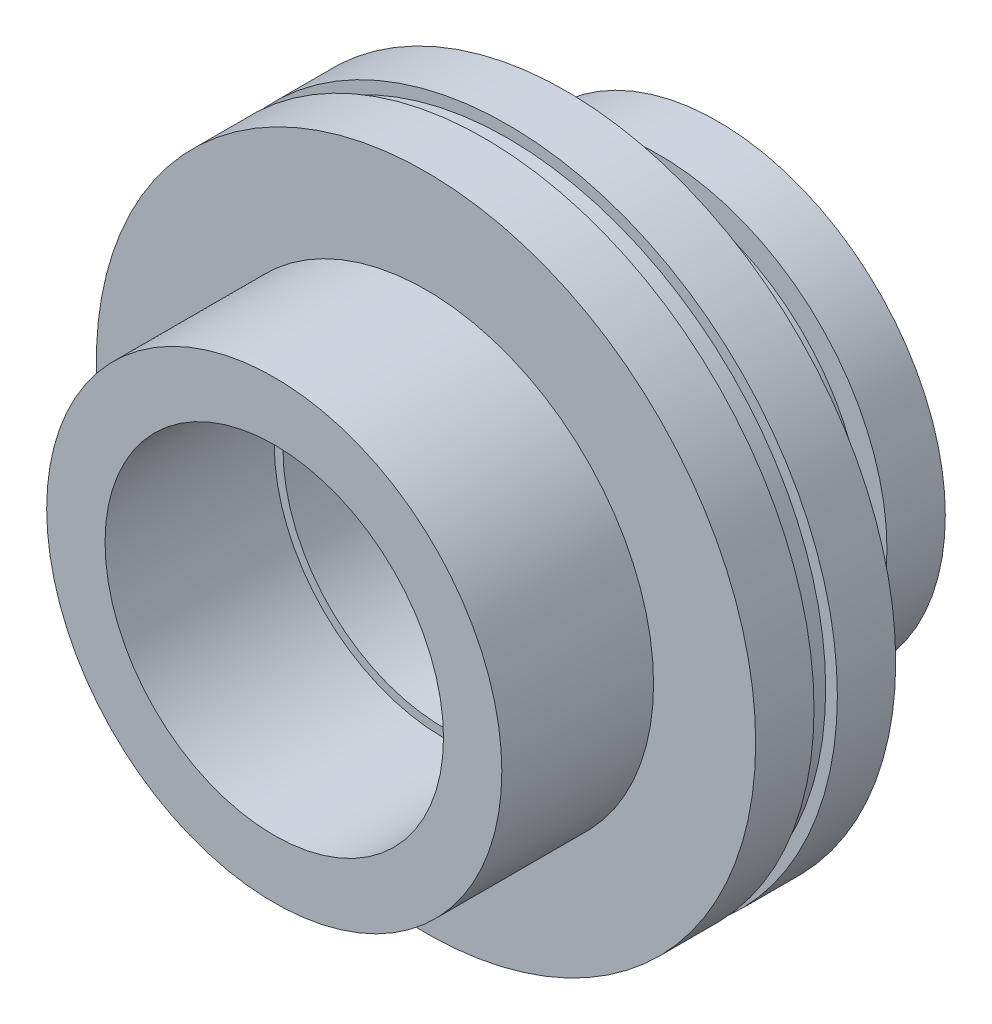
from build123d import *

# Parameters (mm, degrees)
EXTRUDE_1_DEPTH          = 12
EXTRUDE_1_DEPTH_BACK     = 12
SKETCH_1_R               = 56.5
CUT_EXTRUDE_1_DEPTH      = 2
CUT_EXTRUDE_1_DEPTH_BACK = 2
SKETCH_2_R               = 74.899602785
SKETCH_2_R_2             = 54.5
SKETCH_3_R               = 39
EXTRUDE_2_DEPTH          = 26
CUT_EXTRUDE_2_DEPTH      = 3
CUT_EXTRUDE_2_DEPTH_BACK = 3
SKETCH_4_R               = 52.483360518
SKETCH_4_R_2             = 35
SKETCH_5_R               = 27.5
CUT_EXTRUDE_3_DEPTH      = 80
SKETCH_6_R               = 29
CUT_EXTRUDE_4_DEPTH      = 50


with BuildPart() as part:
    # 草图1 → 凸台-拉伸1 (new, two sides: drawn at the far end of the back side and taken through both)
    with BuildSketch(Plane.XY.offset(-EXTRUDE_1_DEPTH_BACK)):
        Circle(SKETCH_1_R)
    extrude(amount=EXTRUDE_1_DEPTH + EXTRUDE_1_DEPTH_BACK)

    # 草图2 → 切除-拉伸1 (cut, two sides: drawn at the far end of the back side and taken through both)
    with BuildSketch(Plane.XY.offset(-CUT_EXTRUDE_1_DEPTH_BACK)):
        Circle(SKETCH_2_R)
        Circle(SKETCH_2_R_2, mode=Mode.SUBTRACT)
    extrude(amount=CUT_EXTRUDE_1_DEPTH + CUT_EXTRUDE_1_DEPTH_BACK, mode=Mode.SUBTRACT)

    # 草图3 → 凸台-拉伸2 (add)
    with BuildSketch(Plane(origin=(0, 0, -12), x_dir=(-1, 0, 0), z_dir=(0, 0, -1))):
        Circle(SKETCH_3_R)
    extrude_2 = extrude(amount=EXTRUDE_2_DEPTH)

    # 镜向1: 凸台-拉伸2 across plane
    add(extrude_2.mirror(Plane.XY))

    # 草图4 → 切除-拉伸2 (cut, two sides: drawn at the far end of the back side and taken through both)
    with BuildSketch(Plane(origin=(0, 0, -25), x_dir=(-1, 0, 0), z_dir=(0, 0, -1)).offset(-CUT_EXTRUDE_2_DEPTH_BACK)):
        Circle(SKETCH_4_R)
        Circle(SKETCH_4_R_2, mode=Mode.SUBTRACT)
    extrude(amount=CUT_EXTRUDE_2_DEPTH + CUT_EXTRUDE_2_DEPTH_BACK, mode=Mode.SUBTRACT)

    # 草图5 → 切除-拉伸3 (cut)
    with BuildSketch(Plane.XY.offset(38)):
        Circle(SKETCH_5_R)
    extrude(amount=-CUT_EXTRUDE_3_DEPTH, mode=Mode.SUBTRACT)

    # 草图6 → 切除-拉伸4 (cut)
    with BuildSketch(Plane.XY.offset(9)):
        Circle(SKETCH_6_R)
    cut_extrude_4 = extrude(amount=CUT_EXTRUDE_4_DEPTH, mode=Mode.SUBTRACT)

    # 镜向2: 切除-拉伸4 across plane
    add(cut_extrude_4.mirror(Plane.XY), mode=Mode.SUBTRACT)


solid = part.part
